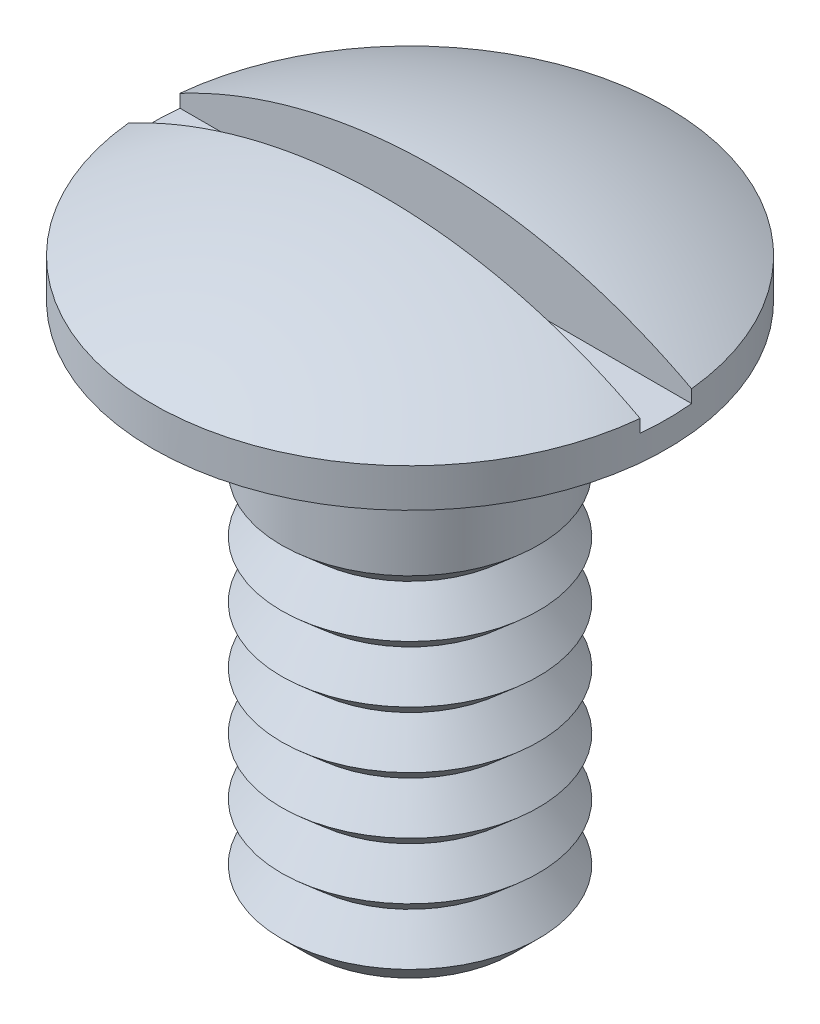
from build123d import *

# Parameters (mm, degrees)
ESQUISSE2_W             = 0.2
ESQUISSE2_H             = 0.6
ENL_V_MAT_EXTRU_1_DEPTH = 1.5
CHANFREIN1_SIZE         = 0.1


with BuildPart() as part:
    # Esquisse1 → Révolution1 (revolve)
    with BuildSketch(Plane(origin=(0, 0, 0), x_dir=(0, 0, -1), z_dir=(1, 0, 0))):
        with BuildLine():
            Line((0, 0), (-0.5, 0))
            Line((-0.5, 0), (-0.5, 2))
            Line((-0.5, 2), (-1, 2))
            Line((-1, 2), (-1, 2.15))
            ThreePointArc((-1, 2.15), (-0.515388203, 2.336552813), (0, 2.4))
            Line((0, 2.4), (0, 0))
        make_face()
    revolve(axis=Axis((0, 0, 0), (0, 1, 0)))

    # Esquisse2 → Enlèv. mat.-Extru.1 (cut, symmetric)
    with BuildSketch(Plane(origin=(0, 0, 0), x_dir=(0, 0, -1), z_dir=(1, 0, 0))):
        with Locations((0, 2.4)):
            Rectangle(ESQUISSE2_W, ESQUISSE2_H)
    extrude(amount=ENL_V_MAT_EXTRU_1_DEPTH, both=True, mode=Mode.SUBTRACT)

    # Chanfrein1
    chanfrein1_edges = [part.edges().sort_by_distance(p)[0] for p in [
        (0, 0, -0.5),
    ]]
    chamfer(chanfrein1_edges, length=CHANFREIN1_SIZE)

    # Esquisse3 → Enlèvement de matière-Révolution1 (revolve, cut)
    with BuildSketch(Plane.XY):
        Polygon((-0.5, 0.1), (-0.390480074, 0.224919634), (-0.5, 0.32093828), (-0.390480074, 0.445857914), (-0.5, 0.541876561), (-0.390480074, 0.666796195), (-0.5, 0.762814841), (-0.390480074, 0.887734475), (-0.5, 0.983753122), (-0.390480074, 1.108672755), (-0.5, 1.204691402), (-0.390480074, 1.329611036), (-0.5, 1.425629682), (-0.822305097, 1.425629682), (-0.822305097, 0.1), align=None)
    revolve(axis=Axis((0, 0, 0), (0, -1, 0)), mode=Mode.SUBTRACT)


solid = part.part
